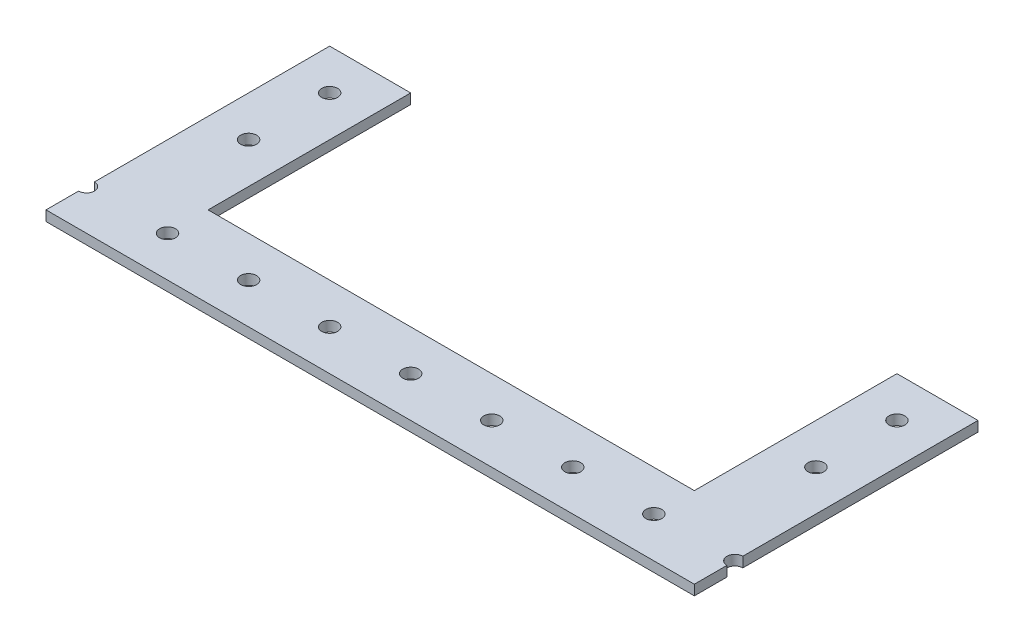
from build123d import *

# Parameters (mm, degrees)
SKETCH1_R           = 2.4892
BOSS_EXTRUDE1_DEPTH = 3.175
SKETCH2_R           = 2.4892
CUT_EXTRUDE1_DEPTH  = 4.175


with BuildPart() as part:
    # Sketch1 → Boss-Extrude1 (new body)
    with BuildSketch(Plane(origin=(0, 0, 0), x_dir=(1, 0, 0), z_dir=(0, 1, 0))):
        with BuildLine():
            Line((-101.6, 10.2108), (-101.6, 0))
            Line((-101.6, 0), (101.6, 0))
            Line((101.6, 0), (101.6, 10.2108))
            ThreePointArc((101.6, 10.2108), (99.1108, 12.7), (101.6, 15.1892))
            Line((101.6, 15.1892), (101.6, 88.9))
            Line((101.6, 88.9), (76.2, 88.9))
            Line((76.2, 88.9), (76.2, 25.4))
            Line((76.2, 25.4), (-76.2, 25.4))
            Line((-76.2, 25.4), (-76.2, 88.9))
            Line((-76.2, 88.9), (-101.6, 88.9))
            Line((-101.6, 88.9), (-101.6, 15.1892))
            ThreePointArc((-101.6, 15.1892), (-99.8398698, 14.4601302), (-99.1108, 12.7))
            ThreePointArc((-99.1108, 12.7), (-99.8398698, 10.9398698), (-101.6, 10.2108))
        make_face()
        with Locations((-76.2, 12.7)):
            Circle(SKETCH1_R, mode=Mode.SUBTRACT)
        with Locations((-50.8, 12.7)):
            Circle(SKETCH1_R, mode=Mode.SUBTRACT)
        with Locations((-25.4, 12.7)):
            Circle(SKETCH1_R, mode=Mode.SUBTRACT)
        with Locations((0, 12.7)):
            Circle(SKETCH1_R, mode=Mode.SUBTRACT)
        with Locations((25.4, 12.7)):
            Circle(SKETCH1_R, mode=Mode.SUBTRACT)
        with Locations((50.8, 12.7)):
            Circle(SKETCH1_R, mode=Mode.SUBTRACT)
        with Locations((76.2, 12.7)):
            Circle(SKETCH1_R, mode=Mode.SUBTRACT)
    extrude(amount=BOSS_EXTRUDE1_DEPTH)

    # Sketch2 → Cut-Extrude1 (cut, through all)
    with BuildSketch(Plane(origin=(0, 3.175, 0), x_dir=(1, 0, 0), z_dir=(0, 1, 0))):
        with Locations((-88.9, 50.8)):
            Circle(SKETCH2_R)
        with Locations((-88.9, 76.2)):
            Circle(SKETCH2_R)
        with Locations((88.9, 76.2)):
            Circle(SKETCH2_R)
        with Locations((88.9, 50.8)):
            Circle(SKETCH2_R)
    extrude(amount=-CUT_EXTRUDE1_DEPTH, mode=Mode.SUBTRACT)


solid = part.part
